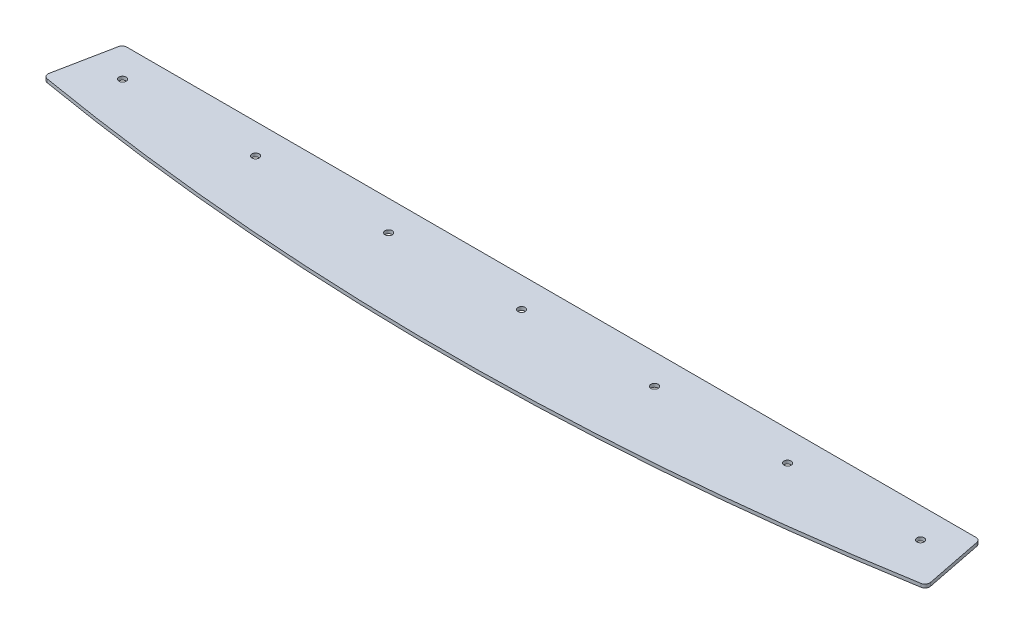
from build123d import *

# Parameters (mm, degrees)
SKETCH1_R           = 3
BOSS_EXTRUDE1_DEPTH = 2.8
FILLET1_R           = 4


with BuildPart() as part:
    # Sketch1 → Boss-Extrude1 (new body)
    with BuildSketch(Plane(origin=(0, 0, 0), x_dir=(1, 0, 0), z_dir=(0, 1, 0))):
        with BuildLine():
            Line((-354.423555473, -2063.72823662), (-365.363735679, -2118.72823662))
            ThreePointArc((-365.363735679, -2118.72823662), (0, -2150), (365.363735679, -2118.72823662))
            Line((365.363735679, -2118.72823662), (354.423555473, -2063.72823662))
            Line((354.423555473, -2063.72823662), (-354.423555473, -2063.72823662))
        make_face()
        with Locations((0, -2088.423050098)):
            Circle(SKETCH1_R, mode=Mode.SUBTRACT)
        with Locations((110, -2088.423050098)):
            Circle(SKETCH1_R, mode=Mode.SUBTRACT)
        with Locations((220, -2088.423050098)):
            Circle(SKETCH1_R, mode=Mode.SUBTRACT)
        with Locations((330, -2088.423050098)):
            Circle(SKETCH1_R, mode=Mode.SUBTRACT)
        with Locations((-110, -2088.423050098)):
            Circle(SKETCH1_R, mode=Mode.SUBTRACT)
        with Locations((-220, -2088.423050098)):
            Circle(SKETCH1_R, mode=Mode.SUBTRACT)
        with Locations((-330, -2088.423050098)):
            Circle(SKETCH1_R, mode=Mode.SUBTRACT)
    extrude(amount=BOSS_EXTRUDE1_DEPTH)

    # Fillet1
    fillet1_edges = [part.edges().sort_by_distance(p)[0] for p in [
        (-365.363735679, 1.4, 2118.72823662),
        (-354.423555473, 1.4, 2063.72823662),
        (354.423555473, 1.4, 2063.72823662),
        (365.363735679, 1.4, 2118.72823662),
    ]]
    fillet(fillet1_edges, radius=FILLET1_R)


solid = part.part
